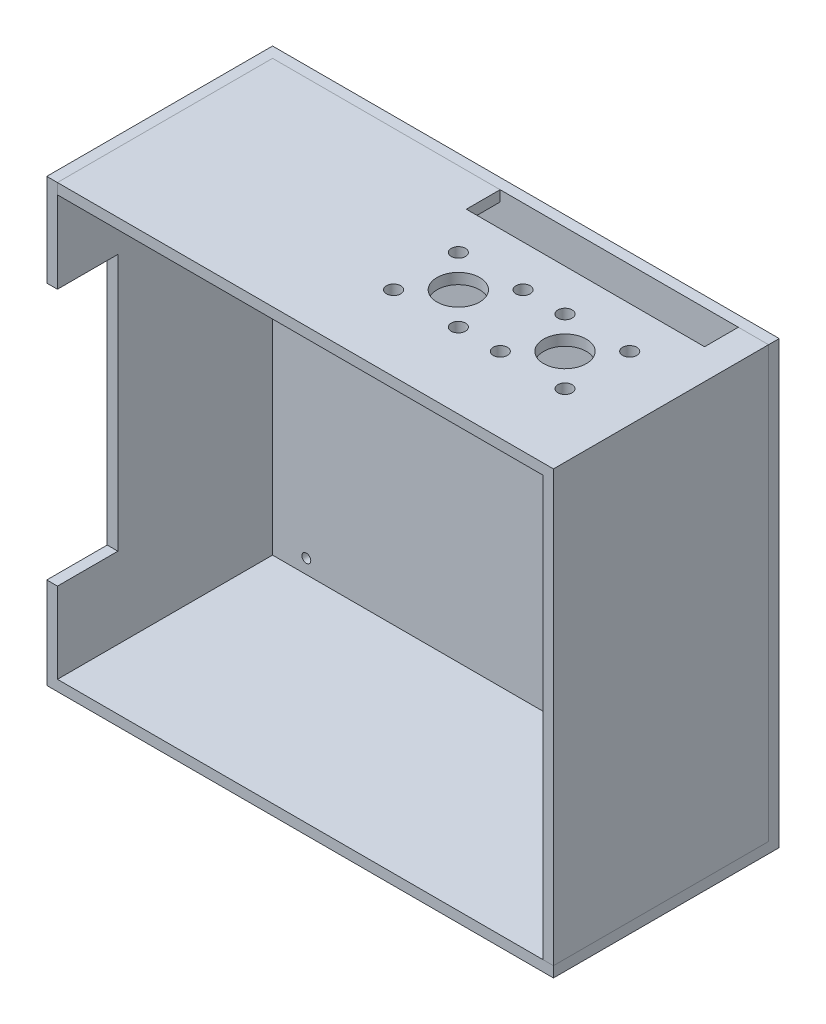
from build123d import *

# Parameters (mm, degrees)
SALIENTE_EXTRUIR1_DEPTH = 124
CROQUIS2_W              = 142.5
CROQUIS2_H              = 63.5
SALIENTE_EXTRUIR2_DEPTH = 3
CROQUIS3_W              = 17
CROQUIS3_H              = 72.3
CORTAR_EXTRUIR1_DEPTH   = 3
CROQUIS4_W              = 139.5
CROQUIS4_H              = 60.5
SALIENTE_EXTRUIR4_DEPTH = 3
CROQUIS5_W              = 60.5
CROQUIS5_H              = 118
SALIENTE_EXTRUIR5_DEPTH = 3
CROQUIS6_R              = 1.25
CORTAR_EXTRUIR2_DEPTH   = 3
CROQUIS7_W              = 67
CROQUIS7_H              = 9.5
CORTAR_EXTRUIR3_DEPTH   = 3
CROQUIS9_R              = 1.25
CORTAR_EXTRUIR6_DEPTH   = 3
CROQUIS10_R             = 6
CROQUIS10_R_2           = 2
CORTAR_EXTRUIR7_DEPTH   = 10


with BuildPart() as part:
    # Croquis1 → Saliente-Extruir1 (new body)
    with BuildSketch(Plane(origin=(0, 0, 0), x_dir=(1, 0, 0), z_dir=(0, 1, 0))):
        Polygon((-68.25, -28.75), (-68.25, 28.75), (68.25, 28.75), (71.25, 28.75), (71.25, 31.75), (-71.25, 31.75), (-71.25, -31.75), (-68.25, -31.75), align=None)
    extrude(amount=SALIENTE_EXTRUIR1_DEPTH)

    # Croquis2 → Saliente-Extruir2 (add)
    with BuildSketch(Plane.XZ):
        Rectangle(CROQUIS2_W, CROQUIS2_H)
    extrude(amount=-SALIENTE_EXTRUIR2_DEPTH)

    # Croquis3 → Cortar-Extruir1 (cut)
    with BuildSketch(Plane.ZY.offset(71.25)):
        with Locations((23.25, 61.85)):
            Rectangle(CROQUIS3_W, CROQUIS3_H)
    extrude(amount=-CORTAR_EXTRUIR1_DEPTH, mode=Mode.SUBTRACT)

    # Croquis6 → Cortar-Extruir2 (cut)
    with BuildSketch(Plane(origin=(0, 0, -31.75), x_dir=(-1, 0, 0), z_dir=(0, 0, -1))):
        with Locations((-58.75, 117)):
            Circle(CROQUIS6_R)
        with Locations((58.75, 117)):
            Circle(CROQUIS6_R)
    extrude(amount=-CORTAR_EXTRUIR2_DEPTH, mode=Mode.SUBTRACT)

    # Croquis9 → Cortar-Extruir6 (cut)
    with BuildSketch(Plane(origin=(0, 0, -31.75), x_dir=(-1, 0, 0), z_dir=(0, 0, -1))):
        with Locations((58.75, 7)):
            Circle(CROQUIS9_R)
        with Locations((-58.75, 7)):
            Circle(CROQUIS9_R)
    extrude(amount=-CORTAR_EXTRUIR6_DEPTH, mode=Mode.SUBTRACT)


with BuildPart() as body_2:
    # Croquis4 → Saliente-Extruir4 (new body)
    with BuildSketch(Plane(origin=(0, 124, 0), x_dir=(1, 0, 0), z_dir=(0, 1, 0))):
        with Locations((1.5, -1.5)):
            Rectangle(CROQUIS4_W, CROQUIS4_H)
    extrude(amount=-SALIENTE_EXTRUIR4_DEPTH)

    # Croquis7 → Cortar-Extruir3 (cut)
    with BuildSketch(Plane(origin=(0, 124, 0), x_dir=(1, 0, 0), z_dir=(0, 1, 0))):
        with Locations((29.25, 24)):
            Rectangle(CROQUIS7_W, CROQUIS7_H)
    extrude(amount=-CORTAR_EXTRUIR3_DEPTH, mode=Mode.SUBTRACT)


with BuildPart() as body_3:
    # Croquis5 → Saliente-Extruir5 (new body)
    with BuildSketch(Plane(origin=(71.25, 0, 0), x_dir=(0, 0, -1), z_dir=(1, 0, 0))):
        with Locations((-1.5, 62)):
            Rectangle(CROQUIS5_W, CROQUIS5_H)
    extrude(amount=-SALIENTE_EXTRUIR5_DEPTH)

    # Combinar1: union body 2
    add(body_2.part)

    # Croquis10 → Cortar-Extruir7 (cut)
    with BuildSketch(Plane(origin=(0, 124, 0), x_dir=(1, 0, 0), z_dir=(0, 1, 0))):
        with Locations((14.25, -1.5)):
            Circle(CROQUIS10_R)
        with Locations((23.35, 7.6)):
            Circle(CROQUIS10_R_2)
        with Locations((5.15, 7.6)):
            Circle(CROQUIS10_R_2)
        with Locations((5.15, -10.6)):
            Circle(CROQUIS10_R_2)
        with Locations((23.35, -10.6)):
            Circle(CROQUIS10_R_2)
        with Locations((44.25, -1.5)):
            Circle(CROQUIS10_R)
        with Locations((53.35, 7.6)):
            Circle(CROQUIS10_R_2)
        with Locations((35.15, 7.6)):
            Circle(CROQUIS10_R_2)
        with Locations((35.15, -10.6)):
            Circle(CROQUIS10_R_2)
        with Locations((53.35, -10.6)):
            Circle(CROQUIS10_R_2)
    extrude(amount=-CORTAR_EXTRUIR7_DEPTH, mode=Mode.SUBTRACT)


solid = Compound([part.part, body_3.part])
